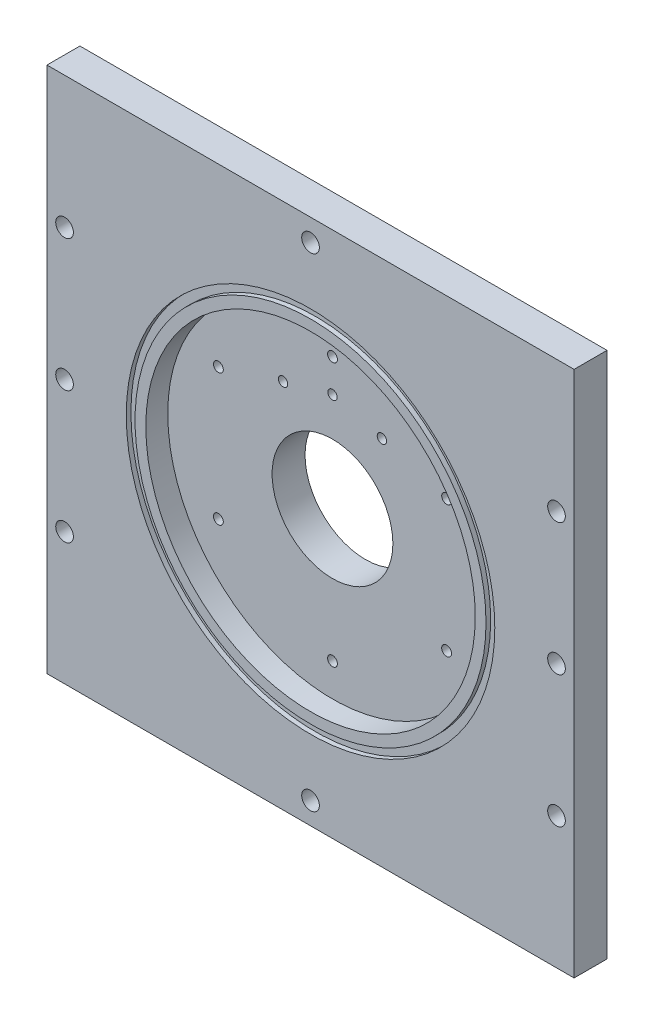
from build123d import *

# Parameters (mm, degrees)
SKETCH1_W                                       = 152.4
SKETCH1_H                                       = 152.4
BOSS_EXTRUDE1_DEPTH                             = 9.525
SKETCH4_W                                       = 63.5
SKETCH4_H                                       = 6.35
CBORE_FOR_10_SOCKET_HEAD_CAP_SCREW1_D           = 5.1054
CBORE_FOR_10_SOCKET_HEAD_CAP_SCREW1_CBORE_D     = 9.525
CBORE_FOR_10_SOCKET_HEAD_CAP_SCREW1_CBORE_DEPTH = 4.826
SKETCH22_R                                      = 47.625
CUT_EXTRUDE3_DEPTH                              = 6.35
SKETCH23_R                                      = 53.2765
SKETCH23_R_2                                    = 50.7365
CUT_EXTRUDE4_DEPTH                              = 1.3462
SKETCH24_R                                      = 17.4625
CUT_EXTRUDE5_DEPTH                              = 25.4
CIRPATTERN1_COUNT                               = 6
SKETCH28_R                                      = 0.635
CUT_EXTRUDE6_DEPTH                              = 10.525
F_6_32_TAPPED_HOLE1_D                           = 2.7051
CIRPATTERN2_COUNT                               = 2
CIRPATTERN2_ANGLE                               = 30
CIRPATTERN3_COUNT                               = 2
CIRPATTERN3_ANGLE                               = 30


with BuildPart() as part:
    # Sketch1 → Boss-Extrude1 (new body)
    with BuildSketch(Plane(origin=(0, 0, 0), x_dir=(-1, 0, 0), z_dir=(0, 0, -1))):
        Rectangle(SKETCH1_W, SKETCH1_H)
    extrude(amount=-BOSS_EXTRUDE1_DEPTH)

    # Sketch4 → Revolve1 (revolve)
    with BuildSketch(Plane(origin=(0, 0, 0), x_dir=(1, 0, 0), z_dir=(0, 1, 0))):
        with Locations((31.75, 3.175)):
            Rectangle(SKETCH4_W, SKETCH4_H)
    revolve(axis=Axis((0, 0, -6.35), (0, 0, 1)))

    # CBORE for #10 Socket Head Cap Screw1 (through all)
    with Locations(Plane(origin=(0, 0, 0), x_dir=(-1, 0, 0), z_dir=(0, 0, -1))):
        with Locations((71.12, 38.1), (71.12, -38.1), (-71.12, 38.1), (-71.12, -38.1), (0, 69.85), (0, -69.85), (71.12, 0), (-71.12, 0)):
            CounterBoreHole(CBORE_FOR_10_SOCKET_HEAD_CAP_SCREW1_D / 2, CBORE_FOR_10_SOCKET_HEAD_CAP_SCREW1_CBORE_D / 2, CBORE_FOR_10_SOCKET_HEAD_CAP_SCREW1_CBORE_DEPTH)

    # Sketch22 → Cut-Extrude3 (cut)
    with BuildSketch(Plane.XY.offset(9.525)):
        Circle(SKETCH22_R)
    extrude(amount=-CUT_EXTRUDE3_DEPTH, mode=Mode.SUBTRACT)

    # Sketch23 → Cut-Extrude4 (cut)
    with BuildSketch(Plane.XY.offset(9.525)):
        Circle(SKETCH23_R)
        Circle(SKETCH23_R_2, mode=Mode.SUBTRACT)
    extrude(amount=-CUT_EXTRUDE4_DEPTH, mode=Mode.SUBTRACT)

    # Sketch24 → Cut-Extrude5 (cut)
    with BuildSketch(Plane.XY.offset(3.175)):
        Circle(SKETCH24_R)
    extrude(amount=-CUT_EXTRUDE5_DEPTH, mode=Mode.SUBTRACT)

    # Sketch25 → #4-40 Tapped Hole1 (revolve, cut)
    with BuildSketch(Plane(origin=(0, 38.1, 3.175), x_dir=(0, -1, 0), z_dir=(1, 0, 0))):
        Polygon((0, 0), (0, 8.273752758), (1.1303, 7.5946), (1.1303, 5.6896), (1.4224, 5.6896), (1.4224, 0), align=None)
    f_4_40_tapped_hole1 = revolve(axis=Axis((0, 38.1, 9.525), (0, 0, -1)), mode=Mode.SUBTRACT)

    # CirPattern1: #4-40 Tapped Hole1 ×6 about axis
    cirpattern1_axis = Axis((0, 0, 0), (0, 0, 1))
    for i in range(1, CIRPATTERN1_COUNT):
        add(f_4_40_tapped_hole1.rotate(cirpattern1_axis, i * 360 / CIRPATTERN1_COUNT), mode=Mode.SUBTRACT)

    # Sketch28 → Cut-Extrude6 (cut, through all)
    with BuildSketch(Plane.XY.offset(3.175)):
        with Locations((0, 28.575)):
            Circle(SKETCH28_R)
    cut_extrude6 = extrude(amount=-CUT_EXTRUDE6_DEPTH, mode=Mode.SUBTRACT)

    # #6-32 Tapped Hole1 (through all)
    with Locations(Plane.XY.offset(3.175)):
        with Locations((0, 28.575)):
            f_6_32_tapped_hole1 = Hole(F_6_32_TAPPED_HOLE1_D / 2)

    # CirPattern2: Cut-Extrude6, #6-32 Tapped Hole1 ×2 about axis
    cirpattern2_axis = Axis((0, 0, 3.175), (0, 0, -1))
    for i in range(1, CIRPATTERN2_COUNT):
        add(cut_extrude6.rotate(cirpattern2_axis, i * CIRPATTERN2_ANGLE / (CIRPATTERN2_COUNT - 1)), mode=Mode.SUBTRACT)
        add(f_6_32_tapped_hole1.rotate(cirpattern2_axis, i * CIRPATTERN2_ANGLE / (CIRPATTERN2_COUNT - 1)), mode=Mode.SUBTRACT)

    # CirPattern3: Cut-Extrude6, #6-32 Tapped Hole1 ×2 about axis
    cirpattern3_axis = Axis((0, 0, 3.175), (0, 0, 1))
    for i in range(1, CIRPATTERN3_COUNT):
        add(cut_extrude6.rotate(cirpattern3_axis, i * CIRPATTERN3_ANGLE / (CIRPATTERN3_COUNT - 1)), mode=Mode.SUBTRACT)
        add(f_6_32_tapped_hole1.rotate(cirpattern3_axis, i * CIRPATTERN3_ANGLE / (CIRPATTERN3_COUNT - 1)), mode=Mode.SUBTRACT)


solid = part.part
